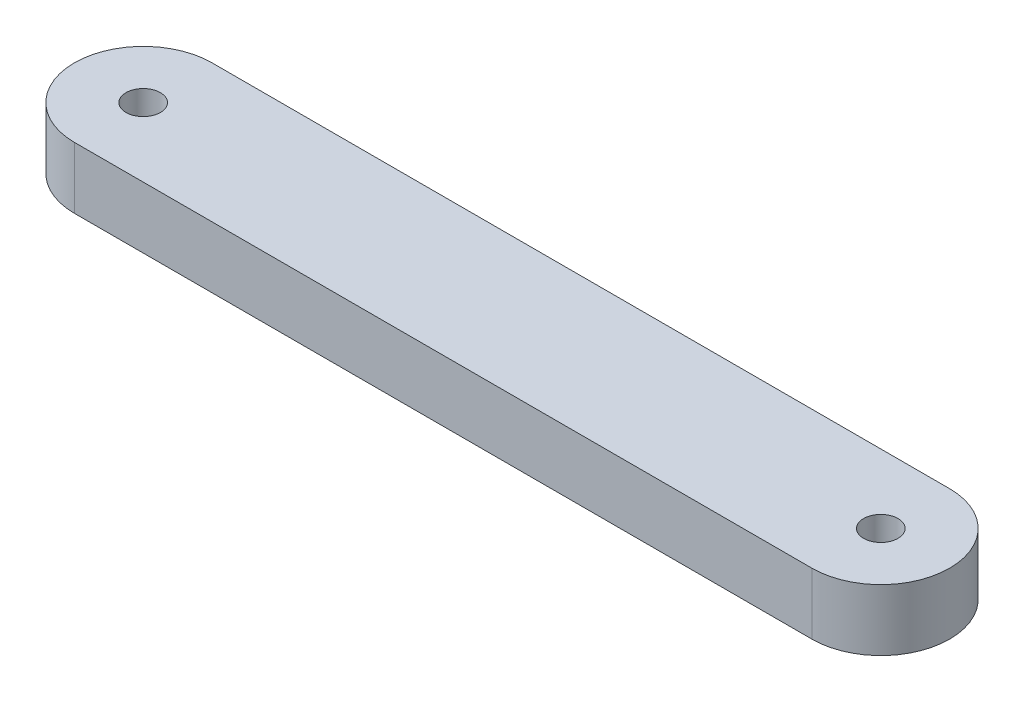
from build123d import *

# Parameters (mm, degrees)
SKETCH_1_R      = 28
SKETCH_1_R_2    = 7
EXTRUDE_1_DEPTH = 25


with BuildPart() as part:
    # 草图1 → 凸台-拉伸1 (new body)
    with BuildSketch(Plane(origin=(0, 0, 0), x_dir=(1, 0, 0), z_dir=(0, 1, 0))):
        with BuildLine():
            Line((150, 28), (-150, 28))
            ThreePointArc((-150, 28), (-130.201010127, 19.798989873), (-122, 0))
            ThreePointArc((-122, 0), (-130.201010127, -19.798989873), (-150, -28))
            Line((-150, -28), (150, -28))
            ThreePointArc((150, -28), (122, 0), (150, 28))
        make_face()
        with Locations((150, 0)):
            Circle(SKETCH_1_R)
        with Locations((150, 0)):
            Circle(SKETCH_1_R_2, mode=Mode.SUBTRACT)
        with Locations((-150, 0)):
            Circle(SKETCH_1_R)
        with Locations((-150, 0)):
            Circle(SKETCH_1_R_2, mode=Mode.SUBTRACT)
    extrude(amount=EXTRUDE_1_DEPTH)


solid = part.part
